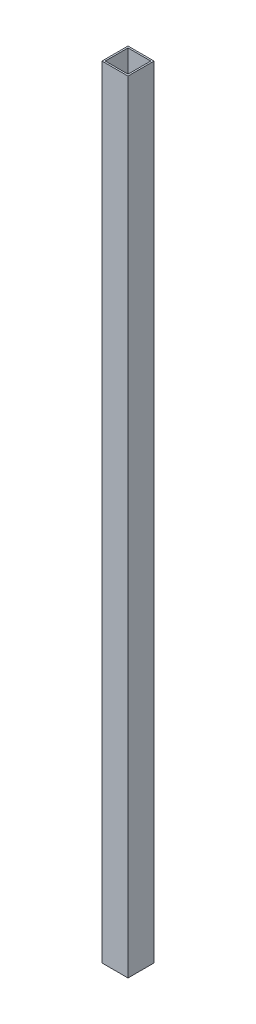
from build123d import *

# Parameters (mm, degrees)
SKETCH1_W           = 25.4
SKETCH1_H           = 25.4
SKETCH1_W_2         = 22.1996
SKETCH1_H_2         = 22.1996
BOSS_EXTRUDE1_DEPTH = 762


with BuildPart() as part:
    # Sketch1 → Boss-Extrude1 (new body)
    with BuildSketch(Plane(origin=(0, 0, 0), x_dir=(1, 0, 0), z_dir=(0, 1, 0))):
        with Locations((12.7, 12.7)):
            Rectangle(SKETCH1_W, SKETCH1_H)
        with Locations((12.7, 12.7)):
            Rectangle(SKETCH1_W_2, SKETCH1_H_2, mode=Mode.SUBTRACT)
    extrude(amount=BOSS_EXTRUDE1_DEPTH)


solid = part.part
